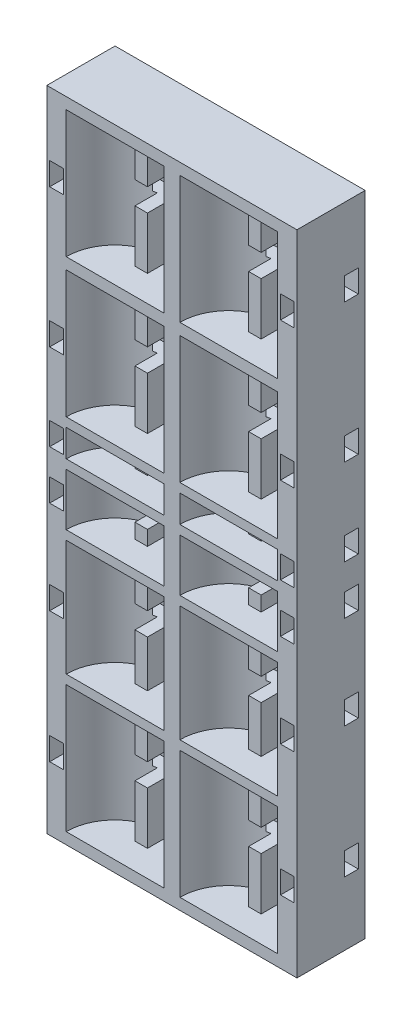
from build123d import *

# Parameters (mm, degrees)
SKETCH1_W               = 110
SKETCH1_H               = 285
BOSS_EXTRUDE1_DEPTH     = 30
SKETCH2_R               = 21.5
CUT_EXTRUDE1_DEPTH      = 286
SKETCH3_W               = 110
SKETCH3_H               = 5
SKETCH3_H_2             = 4
BOSS_EXTRUDE2_DEPTH     = 30
BOSS_EXTRUDE4_START     = -280
SKETCH4_W               = 5.5
SKETCH4_H               = 10
BOSS_EXTRUDE4_DEPTH     = 275
SKETCH5_W               = 6
SKETCH5_H               = 10
CUT_EXTRUDE2_DEPTH      = 27
SKETCH6_W               = 6
SKETCH6_H               = 10
CUT_EXTRUDE3_DEPTH      = 1
CUT_EXTRUDE3_DEPTH_BACK = 111
FILLET1_R               = 5
SKETCH8_W               = 9.219544457
SKETCH8_H               = 10
CUT_EXTRUDE4_DEPTH      = 28
CUT_EXTRUDE5_DEPTH      = 2.6


with BuildPart() as part:
    # Sketch1 → Boss-Extrude1 (new body)
    with BuildSketch(Plane.XY):
        with Locations((5.188679245, -105.235849057)):
            Rectangle(SKETCH1_W, SKETCH1_H)
    extrude(amount=BOSS_EXTRUDE1_DEPTH)

    # Sketch2 → Cut-Extrude1 (cut, through all)
    with BuildSketch(Plane(origin=(0, 37.264150943, 0), x_dir=(1, 0, 0), z_dir=(0, 1, 0))):
        with Locations((-19.811320755, -30)):
            Circle(SKETCH2_R)
        with Locations((30.188679245, -30)):
            Circle(SKETCH2_R)
    extrude(amount=-CUT_EXTRUDE1_DEPTH, mode=Mode.SUBTRACT)

    # Sketch3 → Boss-Extrude2 (add)
    with BuildSketch(Plane(origin=(0, 0, 0), x_dir=(-1, 0, 0), z_dir=(0, 0, -1))):
        with Locations((-5.188679245, 34.764150943)):
            Rectangle(SKETCH3_W, SKETCH3_H)
        with Locations((-5.188679245, -26.235849057)):
            Rectangle(SKETCH3_W, SKETCH3_H)
        with Locations((-5.188679245, -86.735849057)):
            Rectangle(SKETCH3_W, SKETCH3_H_2)
        with Locations((-5.188679245, -245.235849057)):
            Rectangle(SKETCH3_W, SKETCH3_H)
        with Locations((-5.188679245, -184.735849057)):
            Rectangle(SKETCH3_W, SKETCH3_H_2)
        with Locations((-5.188679245, -129.735849057)):
            Rectangle(SKETCH3_W, SKETCH3_H_2)
        with Locations((-5.188679245, -102.735849057)):
            Rectangle(SKETCH3_W, SKETCH3_H_2)
    extrude(amount=-BOSS_EXTRUDE2_DEPTH)

    # Sketch4 → Boss-Extrude4 (add)
    with BuildSketch(Plane(origin=(0, 37.264150943, 0), x_dir=(1, 0, 0), z_dir=(0, 1, 0)).offset(BOSS_EXTRUDE4_START)):
        with Locations((30.188679245, -13.5)):
            Rectangle(SKETCH4_W, SKETCH4_H)
        with Locations((-19.811320755, -13.5)):
            Rectangle(SKETCH4_W, SKETCH4_H)
    extrude(amount=BOSS_EXTRUDE4_DEPTH)

    # Sketch5 → Cut-Extrude2 (cut)
    with BuildSketch(Plane.XY.offset(30)):
        with Locations((-45.561320755, -214.735849057)):
            Rectangle(SKETCH5_W, SKETCH5_H)
        with Locations((-45.561320755, -157.235849057)):
            Rectangle(SKETCH5_W, SKETCH5_H)
        with Locations((-45.561320755, -116.235849057)):
            Rectangle(SKETCH5_W, SKETCH5_H)
        with Locations((-45.561320755, -94.735849057)):
            Rectangle(SKETCH5_W, SKETCH5_H)
        with Locations((-45.561320755, -56.735849057)):
            Rectangle(SKETCH5_W, SKETCH5_H)
        with Locations((-45.561320755, 4.264150943)):
            Rectangle(SKETCH5_W, SKETCH5_H)
    cut_extrude2 = extrude(amount=-CUT_EXTRUDE2_DEPTH, mode=Mode.SUBTRACT)

    # Sketch6 → Cut-Extrude3 (cut, two sides)
    with BuildSketch(Plane.ZY.offset(49.811320755)) as cut_extrude3_sk:
        with Locations((6, -56.735849057)):
            Rectangle(SKETCH6_W, SKETCH6_H)
        with Locations((6, -116.235849057)):
            Rectangle(SKETCH6_W, SKETCH6_H)
        with Locations((6, -94.735849057)):
            Rectangle(SKETCH6_W, SKETCH6_H)
        with Locations((6, -214.735849057)):
            Rectangle(SKETCH6_W, SKETCH6_H)
        with Locations((6, 4.264150943)):
            Rectangle(SKETCH6_W, SKETCH6_H)
        with Locations((6, -157.235849057)):
            Rectangle(SKETCH6_W, SKETCH6_H)
    extrude(amount=CUT_EXTRUDE3_DEPTH, mode=Mode.SUBTRACT)
    extrude(cut_extrude3_sk.sketch, amount=-CUT_EXTRUDE3_DEPTH_BACK, mode=Mode.SUBTRACT)

    # Mirror1: Cut-Extrude2 across plane
    add(cut_extrude2.mirror(Plane(origin=(5.188679245, 0, 0), x_dir=(0, 0, 1), z_dir=(1, 0, 0))), mode=Mode.SUBTRACT)

    # Fillet1
    fillet1_edges = [part.edges().sort_by_distance(p)[0] for p in [
        (-42.561320755, -214.735849057, 9),
        (-42.561320755, -94.735849057, 9),
        (-42.561320755, -56.735849057, 9),
        (-42.561320755, 4.264150943, 9),
        (-42.561320755, -116.235849057, 9),
        (-42.561320755, -157.235849057, 9),
        (52.938679245, 4.264150943, 9),
        (52.938679245, -56.735849057, 9),
        (52.938679245, -94.735849057, 9),
        (52.938679245, -116.235849057, 9),
        (52.938679245, -157.235849057, 9),
        (52.938679245, -214.735849057, 9),
    ]]
    fillet(fillet1_edges, radius=FILLET1_R)

    # Sketch8 → Cut-Extrude4 (cut, through all)
    with BuildSketch(Plane.XY.offset(3)):
        with Locations((-19.811320755, 4.264150943)):
            Rectangle(SKETCH8_W, SKETCH8_H)
        with Locations((-19.811320755, -56.735849057)):
            Rectangle(SKETCH8_W, SKETCH8_H)
        with Locations((-19.811320755, -94.735849057)):
            Rectangle(SKETCH8_W, SKETCH8_H)
        with Locations((-19.811320755, -116.235849057)):
            Rectangle(SKETCH8_W, SKETCH8_H)
        with Locations((-19.811320755, -157.235849057)):
            Rectangle(SKETCH8_W, SKETCH8_H)
        with Locations((-19.811320755, -214.735849057)):
            Rectangle(SKETCH8_W, SKETCH8_H)
    cut_extrude4 = extrude(amount=CUT_EXTRUDE4_DEPTH, mode=Mode.SUBTRACT)

    # Mirror2: Cut-Extrude4 across plane
    add(cut_extrude4.mirror(Plane(origin=(5.188679245, 0, 0), x_dir=(0, 0, 1), z_dir=(1, 0, 0))), mode=Mode.SUBTRACT)

    # Sketch9 → Cut-Extrude5 (cut)
    with BuildSketch(Plane(origin=(0, 0, 0), x_dir=(-1, 0, 0), z_dir=(0, 0, -1))):
        Polygon((28.194740001, -165.835849057), (31.427901508, -165.835849057), (33.044482262, -163.035849057), (31.427901508, -160.235849057), (28.194740001, -160.235849057), (26.578159247, -163.035849057), align=None)
        Polygon((-41.805259999, -165.835849057), (-38.572098492, -165.835849057), (-36.955517738, -163.035849057), (-38.572098492, -160.235849057), (-41.805259999, -160.235849057), (-43.421840753, -163.035849057), align=None)
        Polygon((28.194740001, -53.035849057), (31.427901508, -53.035849057), (33.044482262, -50.235849057), (31.427901508, -47.435849057), (28.194740001, -47.435849057), (26.578159247, -50.235849057), align=None)
        Polygon((-41.805259999, -53.035849057), (-38.572098492, -53.035849057), (-36.955517738, -50.235849057), (-38.572098492, -47.435849057), (-41.805259999, -47.435849057), (-43.421840753, -50.235849057), align=None)
    extrude(amount=-CUT_EXTRUDE5_DEPTH, mode=Mode.SUBTRACT)


solid = part.part
